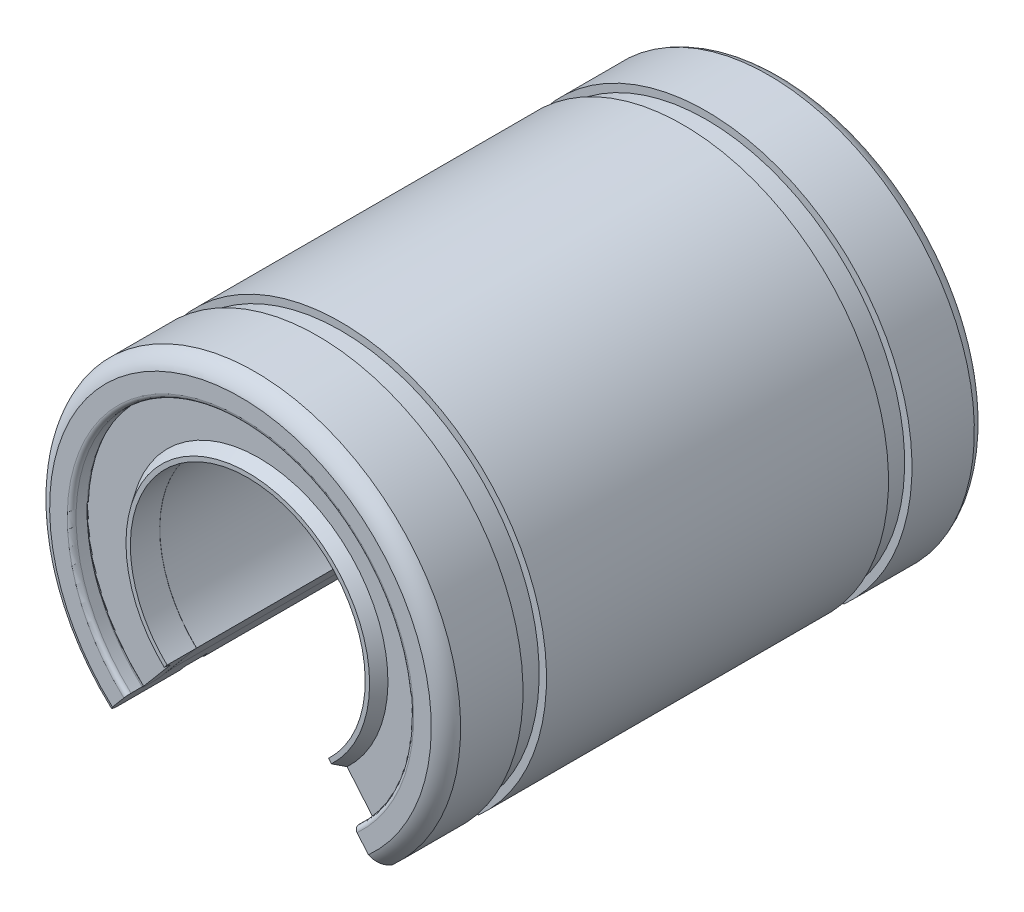
from build123d import *

# Parameters (mm, degrees)
SKETCH_1_W               = 31.98
SKETCH_1_H               = 3
CUT_EXTRUDE_1_DEPTH      = 28.09704781
CUT_EXTRUDE_1_DEPTH_BACK = 28.09704781


with BuildPart() as part:
    # Эскиз1 → Повернуть1 (revolve)
    with BuildSketch(Plane(origin=(0, 0, 0), x_dir=(0, 0, -1), z_dir=(1, 0, 0))):
        with BuildLine():
            Line((-17.25, 8.8), (-18, 8.3))
            Line((-18, 8.3), (-18, 8))
            Line((-18, 8), (-16, 8))
            Line((-16, 8), (-16, 11.7))
            ThreePointArc((-16, 11.7), (-16.087867966, 11.912132034), (-16.3, 12))
            Line((-16.3, 12), (-16.95, 12))
            ThreePointArc((-16.95, 12), (-17.162132034, 11.912132034), (-17.25, 11.7))
            Line((-17.25, 11.7), (-17.25, 8.8))
        make_face()
        with Locations((0, 9.5)):
            Rectangle(SKETCH_1_W, SKETCH_1_H)
        with BuildLine():
            Line((16, 8), (18, 8))
            Line((18, 8), (18, 8.3))
            Line((18, 8.3), (17.25, 8.8))
            Line((17.25, 8.8), (17.25, 11.7))
            ThreePointArc((17.25, 11.7), (17.162132034, 11.912132034), (16.95, 12))
            Line((16.95, 12), (16.3, 12))
            ThreePointArc((16.3, 12), (16.087867966, 11.912132034), (16, 11.7))
            Line((16, 11.7), (16, 8))
        make_face()
    revolve(axis=Axis((0, 0, 43.343199199), (0, 0, -1)))


with BuildPart() as body_2:
    # Эскиз1<3> → Повернуть2 (revolve)
    with BuildSketch(Plane(origin=(0, 0, 0), x_dir=(0, 0, -1), z_dir=(1, 0, 0))):
        with BuildLine():
            Line((-13.25, 14), (-17.5, 14))
            ThreePointArc((-17.5, 14), (-18.125245825, 13.625245825), (-18.5, 13))
            Line((-18.5, 13), (-18.5, 11.8))
            ThreePointArc((-18.5, 11.8), (-18.412132034, 11.587867966), (-18.2, 11.5))
            Line((-18.2, 11.5), (-17.45, 11.5))
            ThreePointArc((-17.45, 11.5), (-17.308578644, 11.558578644), (-17.25, 11.7))
            ThreePointArc((-17.25, 11.7), (-17.162132034, 11.912132034), (-16.95, 12))
            Line((-16.95, 12), (-16.3, 12))
            ThreePointArc((-16.3, 12), (-16.087867966, 11.912132034), (-16, 11.7))
            Line((-16, 11.7), (-16, 11.3))
            ThreePointArc((-16, 11.3), (-15.912132034, 11.087867966), (-15.7, 11))
            Line((-15.7, 11), (15.7, 11))
            ThreePointArc((15.7, 11), (15.912132034, 11.087867966), (16, 11.3))
            Line((16, 11.3), (16, 11.7))
            ThreePointArc((16, 11.7), (16.087867966, 11.912132034), (16.3, 12))
            Line((16.3, 12), (16.95, 12))
            ThreePointArc((16.95, 12), (17.162132034, 11.912132034), (17.25, 11.7))
            ThreePointArc((17.25, 11.7), (17.308578644, 11.558578644), (17.45, 11.5))
            Line((17.45, 11.5), (18.2, 11.5))
            ThreePointArc((18.2, 11.5), (18.412132034, 11.587867966), (18.5, 11.8))
            Line((18.5, 11.8), (18.5, 13))
            ThreePointArc((18.5, 13), (18.125245825, 13.625245825), (17.5, 14))
            Line((17.5, 14), (13.25, 14))
            Line((13.25, 14), (13.25, 13.5))
            Line((13.25, 13.5), (11.65, 13.5))
            Line((11.65, 13.5), (11.65, 14))
            Line((11.65, 14), (-11.65, 14))
            Line((-11.65, 14), (-11.65, 13.5))
            Line((-11.65, 13.5), (-13.25, 13.5))
            Line((-13.25, 13.5), (-13.25, 14))
        make_face()
    revolve(axis=Axis((0, 0, 43.343199199), (0, 0, -1)))


with BuildPart() as cut_extrude_1_tool:
    # Эскиз2 → Вырез-Вытянуть1 (new, two sides: drawn at the far end of the back side and taken through both)
    with BuildSketch(Plane.XY.offset(-CUT_EXTRUDE_1_DEPTH_BACK)):
        Polygon((0, 0.74516974), (12.37266649, -14), (-12.37266649, -14), align=None)
    extrude(amount=CUT_EXTRUDE_1_DEPTH + CUT_EXTRUDE_1_DEPTH_BACK)


with BuildPart() as part_1:
    add(part.part)

    # Вырез-Вытянуть1: cut by cut_extrude_1_tool
    add(cut_extrude_1_tool.part, mode=Mode.SUBTRACT)


with BuildPart() as body_2_1:
    add(body_2.part)

    # Вырез-Вытянуть1: cut by cut_extrude_1_tool
    add(cut_extrude_1_tool.part, mode=Mode.SUBTRACT)


solid = Compound([part_1.part, body_2_1.part])
